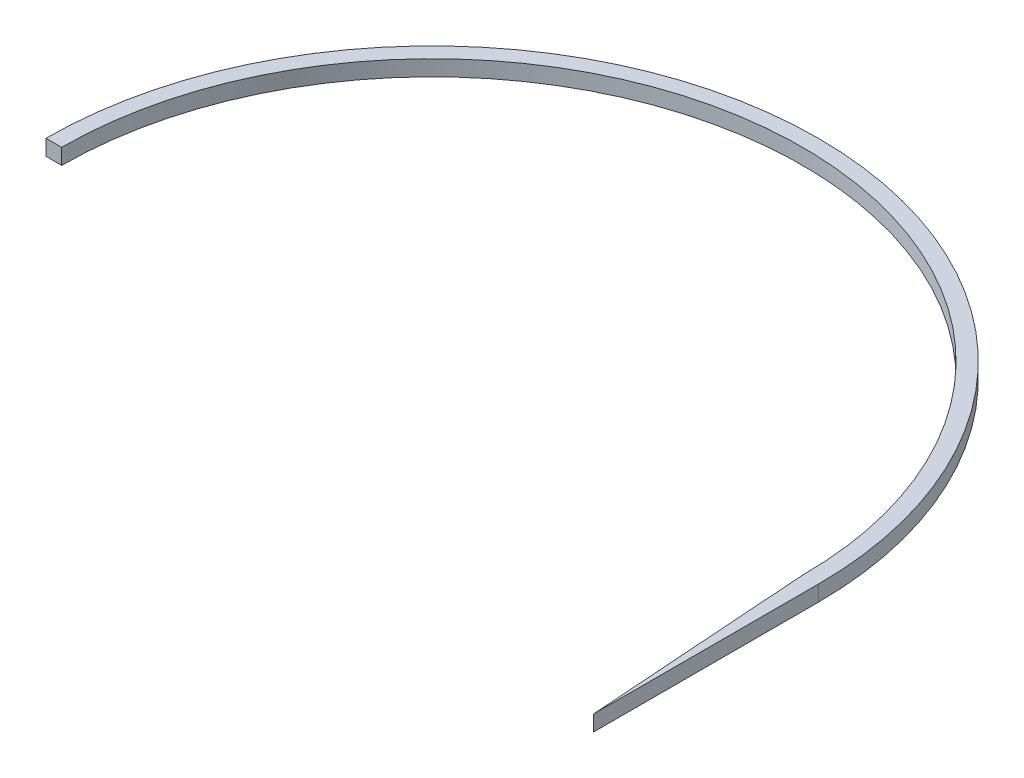
from build123d import *

# Parameters (mm, degrees)
BOSS_EXTRUDE1_DEPTH = 5.7


with BuildPart() as part:
    # Sketch1 → Boss-Extrude1 (new body)
    with BuildSketch(Plane(origin=(0, 0, 0), x_dir=(1, 0, 0), z_dir=(0, 1, 0))):
        with BuildLine():
            Line((-280.7, 115), (-275, 115))
            ThreePointArc((-275, 115), (-140.35, 249.65), (-5.7, 115))
            Line((-5.7, 115), (0, 33.358770855))
            Line((0, 33.358770855), (0, 115))
            ThreePointArc((0, 115), (-140.35, 255.35), (-280.7, 115))
        make_face()
    extrude(amount=BOSS_EXTRUDE1_DEPTH)


solid = part.part
